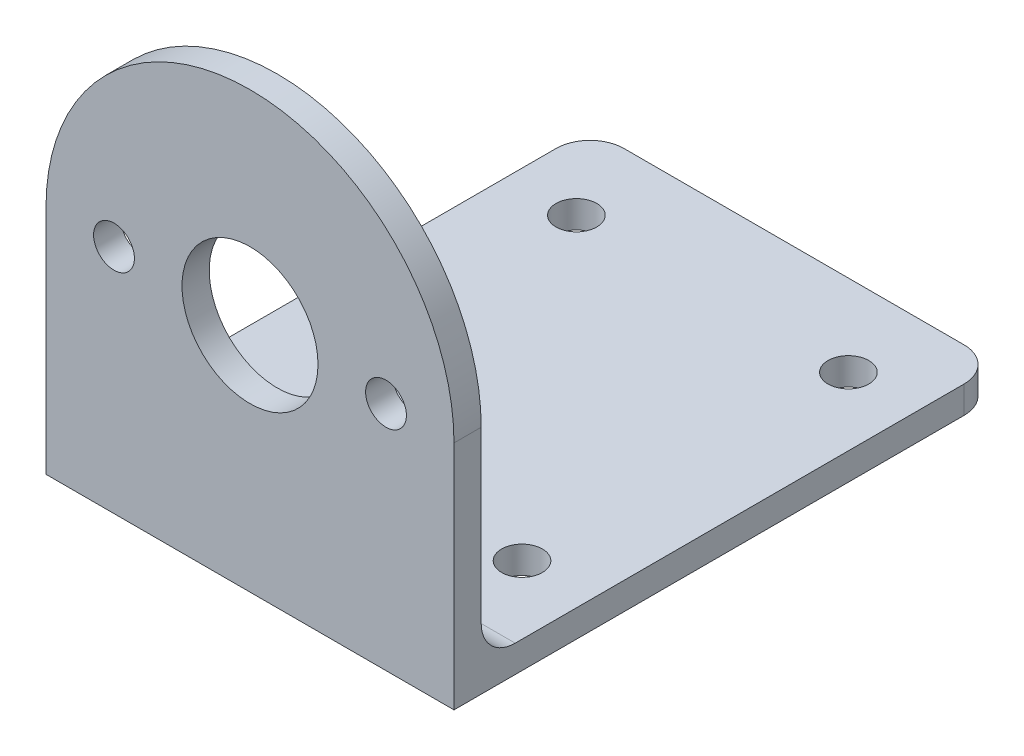
from build123d import *

# Parameters (mm, degrees)
EXTRUDE_1_DEPTH     = 2
SKETCH_2_R          = 5
EXTRUDE_2_DEPTH     = 2
FILLET_1_R          = 2.5
SKETCH_3_R          = 1.5
CUT_EXTRUDE_1_DEPTH = 12
SKETCH_4_R          = 1.5
CUT_EXTRUDE_2_DEPTH = 10


with BuildPart() as part:
    # 草图1 → 凸台-拉伸1 (new body)
    with BuildSketch(Plane(origin=(0, 0, 0), x_dir=(1, 0, 0), z_dir=(0, 1, 0))):
        with BuildLine():
            Line((-12.5, 40), (12.5, 40))
            ThreePointArc((12.5, 40), (14.267766953, 39.267766953), (15, 37.5))
            Line((15, 37.5), (15, 0))
            Line((15, 0), (-15, 0))
            Line((-15, 0), (-15, 37.5))
            ThreePointArc((-15, 37.5), (-14.267766953, 39.267766953), (-12.5, 40))
        make_face()
    extrude(amount=EXTRUDE_1_DEPTH)

    # 草图2 → 凸台-拉伸2 (add)
    with BuildSketch(Plane.XY):
        with BuildLine():
            Line((-15, 17), (-15, 2))
            Line((-15, 2), (15, 2))
            Line((15, 2), (15, 17))
            ThreePointArc((15, 17), (0, 32), (-15, 17))
        make_face()
        with Locations((0, 17)):
            Circle(SKETCH_2_R, mode=Mode.SUBTRACT)
    extrude(amount=-EXTRUDE_2_DEPTH)

    # 圆角1
    fillet_1_edges = [part.edges().sort_by_distance(p)[0] for p in [
        (0, 2, -2),
    ]]
    fillet(fillet_1_edges, radius=FILLET_1_R)

    # 草图3 → 切除-拉伸1 (cut)
    with BuildSketch(Plane.XZ):
        with Locations((10, -10)):
            Circle(SKETCH_3_R)
        with Locations((-10, -10)):
            Circle(SKETCH_3_R)
        with Locations((-10, -34)):
            Circle(SKETCH_3_R)
        with Locations((10, -34)):
            Circle(SKETCH_3_R)
    extrude(amount=-CUT_EXTRUDE_1_DEPTH, mode=Mode.SUBTRACT)

    # 草图4 → 切除-拉伸2 (cut)
    with BuildSketch(Plane.XY):
        with Locations((10, 17)):
            Circle(SKETCH_4_R)
        with Locations((-10, 17)):
            Circle(SKETCH_4_R)
    extrude(amount=-CUT_EXTRUDE_2_DEPTH, mode=Mode.SUBTRACT)


solid = part.part
